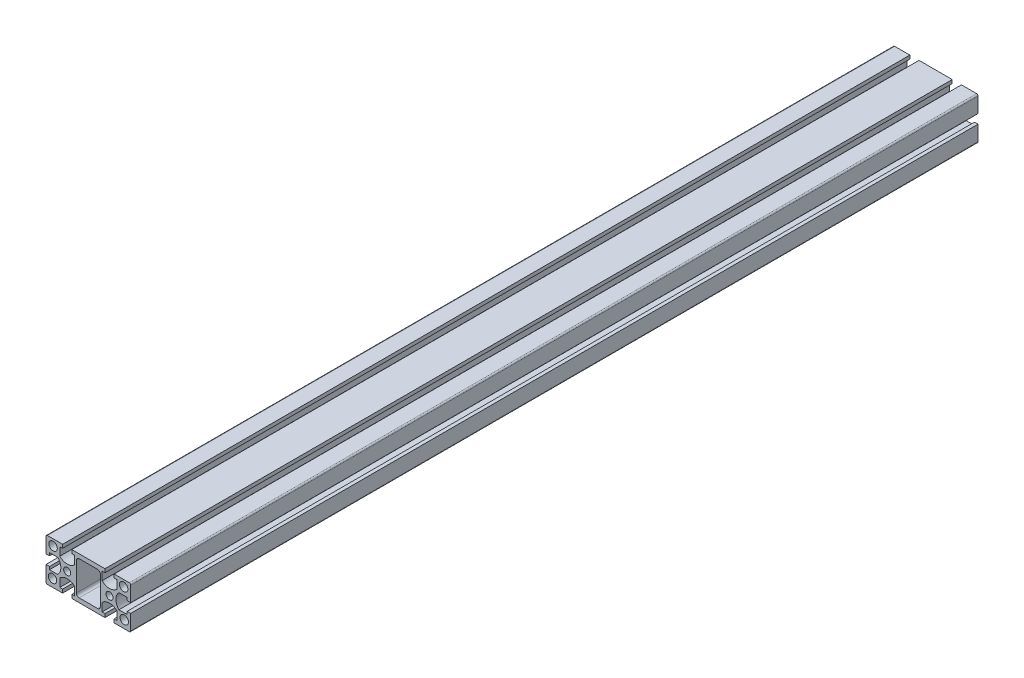
from build123d import *

# Parameters (mm, degrees)
MODEL_R             = 2.5
MODEL_R_2           = 3
BOSS_EXTRUDE1_DEPTH = 600


with BuildPart() as part:
    # Model → Boss-Extrude1 (new body)
    with BuildSketch(Plane.XY):
        with BuildLine():
            Line((-27.5, 3.25), (-30, 3.25))
            Line((-30, 3.25), (-30, 14))
            ThreePointArc((-30, 14), (-29.707106781, 14.707106781), (-29, 15))
            Line((-29, 15), (-18.25, 15))
            Line((-18.25, 15), (-18.25, 12.5))
            Line((-18.25, 12.5), (-20.25, 12.5))
            Line((-20.25, 12.5), (-20.25, 6.643928679))
            ThreePointArc((-20.25, 6.643928679), (-15, 4.5), (-9.75, 6.643928679))
            Line((-9.75, 6.643928679), (-9.75, 12.5))
            Line((-9.75, 12.5), (-11.75, 12.5))
            Line((-11.75, 12.5), (-11.75, 15))
            Line((-11.75, 15), (11.75, 15))
            Line((11.75, 15), (11.75, 12.5))
            Line((11.75, 12.5), (9.75, 12.5))
            Line((9.75, 12.5), (9.75, 6.643928679))
            ThreePointArc((9.75, 6.643928679), (15, 4.5), (20.25, 6.643928679))
            Line((20.25, 6.643928679), (20.25, 12.5))
            Line((20.25, 12.5), (18.25, 12.5))
            Line((18.25, 12.5), (18.25, 15))
            Line((18.25, 15), (29, 15))
            ThreePointArc((29, 15), (29.707106781, 14.707106781), (30, 14))
            Line((30, 14), (30, 3.25))
            Line((30, 3.25), (27.5, 3.25))
            Line((27.5, 3.25), (27.5, 5.25))
            Line((27.5, 5.25), (21.643928679, 5.25))
            ThreePointArc((21.643928679, 5.25), (19.5, 0), (21.643928679, -5.25))
            Line((21.643928679, -5.25), (27.5, -5.25))
            Line((27.5, -5.25), (27.5, -3.25))
            Line((27.5, -3.25), (30, -3.25))
            Line((30, -3.25), (30, -14))
            ThreePointArc((30, -14), (29.707106781, -14.707106781), (29, -15))
            Line((29, -15), (18.25, -15))
            Line((18.25, -15), (18.25, -12.5))
            Line((18.25, -12.5), (20.25, -12.5))
            Line((20.25, -12.5), (20.25, -6.643928679))
            ThreePointArc((20.25, -6.643928679), (15, -4.5), (9.75, -6.643928679))
            Line((9.75, -6.643928679), (9.75, -12.5))
            Line((9.75, -12.5), (11.75, -12.5))
            Line((11.75, -12.5), (11.75, -15))
            Line((11.75, -15), (-11.75, -15))
            Line((-11.75, -15), (-11.75, -12.5))
            Line((-11.75, -12.5), (-9.75, -12.5))
            Line((-9.75, -12.5), (-9.75, -6.643928679))
            ThreePointArc((-9.75, -6.643928679), (-15, -4.5), (-20.25, -6.643928679))
            Line((-20.25, -6.643928679), (-20.25, -12.5))
            Line((-20.25, -12.5), (-18.25, -12.5))
            Line((-18.25, -12.5), (-18.25, -15))
            Line((-18.25, -15), (-29, -15))
            ThreePointArc((-29, -15), (-29.707106781, -14.707106781), (-30, -14))
            Line((-30, -14), (-30, -3.25))
            Line((-30, -3.25), (-27.5, -3.25))
            Line((-27.5, -3.25), (-27.5, -5.25))
            Line((-27.5, -5.25), (-21.643928679, -5.25))
            ThreePointArc((-21.643928679, -5.25), (-19.5, 0), (-21.643928679, 5.25))
            Line((-21.643928679, 5.25), (-27.5, 5.25))
            Line((-27.5, 5.25), (-27.5, 3.25))
        make_face()
        with Locations((-15, 0)):
            Circle(MODEL_R, mode=Mode.SUBTRACT)
        with Locations((-25, 10.531430074)):
            Circle(MODEL_R_2, mode=Mode.SUBTRACT)
        with Locations((-25.399251578, -9.468569926)):
            Circle(MODEL_R_2, mode=Mode.SUBTRACT)
        with Locations((25.399251578, -9.468569926)):
            Circle(MODEL_R_2, mode=Mode.SUBTRACT)
        with Locations((15, 0)):
            Circle(MODEL_R, mode=Mode.SUBTRACT)
        with Locations((25, 10.531430074)):
            Circle(MODEL_R_2, mode=Mode.SUBTRACT)
        with BuildLine():
            Line((6.5, 12), (-6.5, 12))
            ThreePointArc((-6.5, 12), (-7.914213562, 11.414213562), (-8.5, 10))
            Line((-8.5, 10), (-8.5, -10))
            ThreePointArc((-8.5, -10), (-7.914213562, -11.414213562), (-6.5, -12))
            Line((-6.5, -12), (6.5, -12))
            ThreePointArc((6.5, -12), (7.914213562, -11.414213562), (8.5, -10))
            Line((8.5, -10), (8.5, 10))
            ThreePointArc((8.5, 10), (7.914213562, 11.414213562), (6.5, 12))
        make_face(mode=Mode.SUBTRACT)
    extrude(amount=BOSS_EXTRUDE1_DEPTH)


solid = part.part
